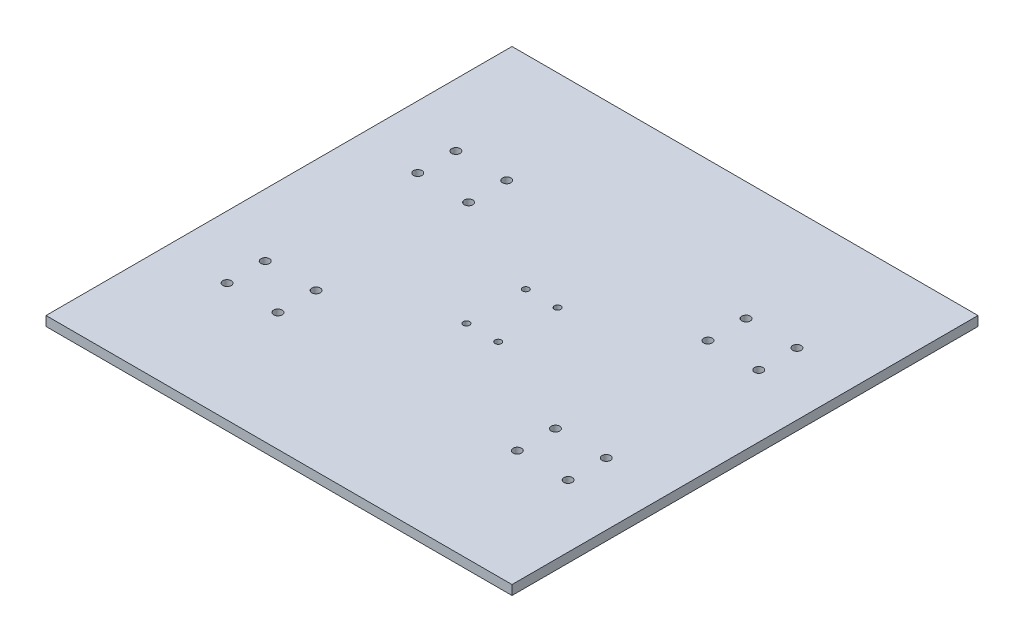
from build123d import *

# Parameters (mm, degrees)
SKETCH1_W           = 220
SKETCH1_H           = 220
BOSS_EXTRUDE1_DEPTH = 4.5
SKETCH2_R           = 1.5
SKETCH2_R_2         = 2
CUT_EXTRUDE1_DEPTH  = 5.5


with BuildPart() as part:
    # Sketch1 → Boss-Extrude1 (new body)
    with BuildSketch(Plane(origin=(0, 0, 0), x_dir=(1, 0, 0), z_dir=(0, 1, 0))):
        Rectangle(SKETCH1_W, SKETCH1_H)
    extrude(amount=BOSS_EXTRUDE1_DEPTH)

    # Sketch2 → Cut-Extrude1 (cut, through all)
    with BuildSketch(Plane(origin=(0, 4.5, 0), x_dir=(1, 0, 0), z_dir=(0, 1, 0))):
        with Locations((-7.5, 14)):
            Circle(SKETCH2_R)
        with Locations((7.5, 14)):
            Circle(SKETCH2_R)
        with Locations((7.5, -14)):
            Circle(SKETCH2_R)
        with Locations((-7.5, -14)):
            Circle(SKETCH2_R)
        with Locations((-80.5, 54)):
            Circle(SKETCH2_R_2)
        with Locations((-80.5, 36)):
            Circle(SKETCH2_R_2)
        with Locations((-56.5, 36)):
            Circle(SKETCH2_R_2)
        with Locations((-56.5, 54)):
            Circle(SKETCH2_R_2)
        with Locations((-56.5, -36)):
            Circle(SKETCH2_R_2)
        with Locations((-56.5, -54)):
            Circle(SKETCH2_R_2)
        with Locations((-80.5, -54)):
            Circle(SKETCH2_R_2)
        with Locations((-80.5, -36)):
            Circle(SKETCH2_R_2)
        with Locations((56.5, -36)):
            Circle(SKETCH2_R_2)
        with Locations((56.5, -54)):
            Circle(SKETCH2_R_2)
        with Locations((80.5, -54)):
            Circle(SKETCH2_R_2)
        with Locations((80.5, -36)):
            Circle(SKETCH2_R_2)
        with Locations((80.5, 36)):
            Circle(SKETCH2_R_2)
        with Locations((80.5, 54)):
            Circle(SKETCH2_R_2)
        with Locations((56.5, 54)):
            Circle(SKETCH2_R_2)
        with Locations((56.5, 36)):
            Circle(SKETCH2_R_2)
    extrude(amount=-CUT_EXTRUDE1_DEPTH, mode=Mode.SUBTRACT)


solid = part.part
